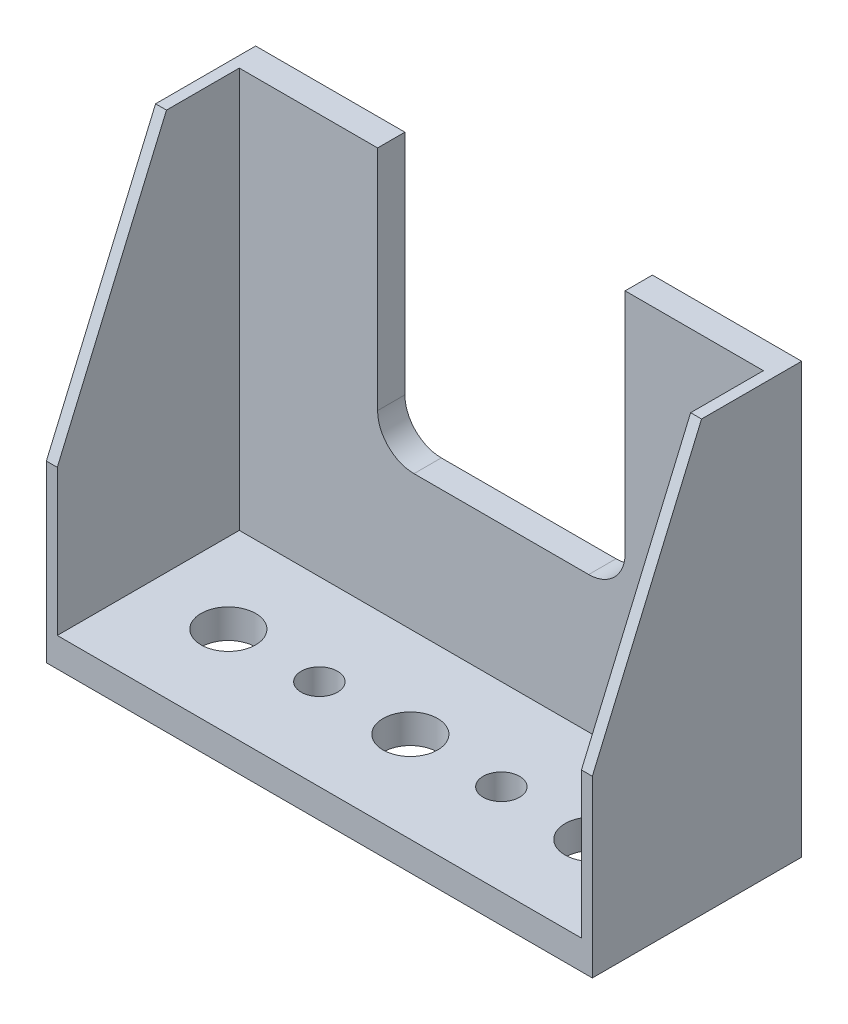
from build123d import *

# Parameters (mm, degrees)
SKETCH3_W               = 30
SKETCH3_H               = 22
BOSS_EXTRUDE1_DEPTH     = 1.5
SKETCH4_W               = 0.6
SKETCH4_H               = 22
BOSS_EXTRUDE2_DEPTH     = 10
CUT_EXTRUDE1_DEPTH      = 1
CUT_EXTRUDE1_DEPTH_BACK = 31
SKETCH6_W               = 30
SKETCH6_H               = 11.5
BOSS_EXTRUDE3_DEPTH     = 1.6
SKETCH7_W               = 13.6
SKETCH7_H               = 14.5
CUT_EXTRUDE2_DEPTH      = 1.6
FILLET1_R               = 2
SKETCH8_R               = 1.5
SKETCH8_R_2             = 1
CUT_EXTRUDE3_DEPTH      = 1.6


with BuildPart() as part:
    # Sketch3 → Boss-Extrude1 (new body)
    with BuildSketch(Plane.XY):
        Rectangle(SKETCH3_W, SKETCH3_H)
    extrude(amount=BOSS_EXTRUDE1_DEPTH)

    # Sketch4 → Boss-Extrude2 (add)
    with BuildSketch(Plane.XY.offset(1.5)):
        with Locations((-14.7, 0)):
            Rectangle(SKETCH4_W, SKETCH4_H)
    boss_extrude2 = extrude(amount=BOSS_EXTRUDE2_DEPTH)

    # Mirror5: Boss-Extrude2 across plane
    add(boss_extrude2.mirror(Plane(origin=(0, 0, 0), x_dir=(0, 0, 1), z_dir=(1, 0, 0))))

    # Sketch5 → Cut-Extrude1 (cut, two sides)
    with BuildSketch(Plane.ZY.offset(15)) as cut_extrude1_sk:
        Polygon((-16.404677134, 62.110913313), (5.5, 11), (11.5, -3), (33.404677134, -54.110913313), (135.626503761, -10.301559045), (85.817149492, 105.920267582), align=None)
    extrude(amount=CUT_EXTRUDE1_DEPTH, mode=Mode.SUBTRACT)
    extrude(cut_extrude1_sk.sketch, amount=-CUT_EXTRUDE1_DEPTH_BACK, mode=Mode.SUBTRACT)

    # Sketch6 → Boss-Extrude3 (add)
    with BuildSketch(Plane.XZ.offset(11)):
        with Locations((0, 5.75)):
            Rectangle(SKETCH6_W, SKETCH6_H)
    extrude(amount=BOSS_EXTRUDE3_DEPTH)

    # Sketch7 → Cut-Extrude2 (cut)
    with BuildSketch(Plane.XY.offset(1.5)):
        with Locations((0, 3.75)):
            Rectangle(SKETCH7_W, SKETCH7_H)
    extrude(amount=-CUT_EXTRUDE2_DEPTH, mode=Mode.SUBTRACT)

    # Fillet1
    fillet1_edges = [part.edges().sort_by_distance(p)[0] for p in [
        (-6.8, -3.5, 0.75),
        (6.8, -3.5, 0.75),
    ]]
    fillet(fillet1_edges, radius=FILLET1_R)

    # Sketch8 → Cut-Extrude3 (cut)
    with BuildSketch(Plane(origin=(0, -11, 0), x_dir=(1, 0, 0), z_dir=(0, 1, 0))):
        with Locations((0, -6.5)):
            Circle(SKETCH8_R)
        with Locations((-5, -6.5)):
            Circle(SKETCH8_R_2)
        with Locations((-10, -6.5)):
            Circle(SKETCH8_R)
        with Locations((5, -6.5)):
            Circle(SKETCH8_R_2)
        with Locations((10, -6.5)):
            Circle(SKETCH8_R)
    extrude(amount=-CUT_EXTRUDE3_DEPTH, mode=Mode.SUBTRACT)


solid = part.part
